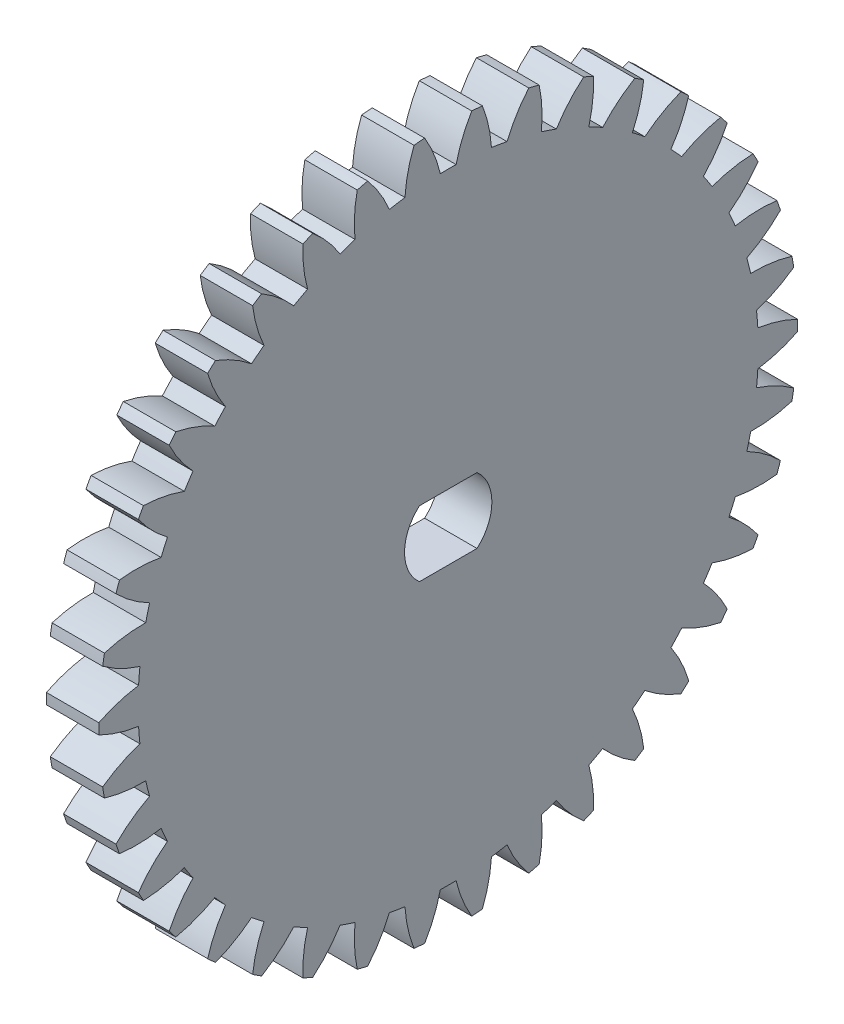
from build123d import *

# Parameters (mm, degrees)
BASPROSKE_W                 = 3
BASPROSKE_H                 = 20
TOOTHCUT_DEPTH              = 29.442925307
TEETHCUTS_COUNT             = 38
TEETHCUTS_ANGLE             = 350.526315789
BORSKE_R                    = 2.5
BORE_DEPTH                  = 50.0000508
SZKIC1_W                    = 8.825815256
SZKIC1_H                    = 6.337105314
SZKIC1_W_2                  = 5.5
SZKIC1_H_2                  = 3.760037978
DODANIE_WYCI_GNI_CIE1_DEPTH = 3


with BuildPart() as part:
    # BasProSke → Base-Revolve (revolve)
    with BuildSketch(Plane(origin=(0, 0, 0), x_dir=(1, 0, 0), z_dir=(0, 1, 0)), mode=Mode.PRIVATE) as base_revolve_sk:
        with Locations((1.5, 10)):
            Rectangle(BASPROSKE_W, BASPROSKE_H)
    revolve(base_revolve_sk.sketch.rotate(Axis((-10, 0, 0), (1, 0, 0)), 180), axis=Axis((-10, 0, 0), (1, 0, 0)))

    # TooCutSke → ToothCut (cut, through all)
    with BuildSketch(Plane(origin=(0, 0, 0), x_dir=(0, 0, -1), z_dir=(1, 0, 0))):
        with BuildLine():
            ThreePointArc((0.451522093, 17.743255868), (0, 17.749), (-0.451522093, 17.743255868))
            ThreePointArc((-0.451522093, 17.743255868), (-0.817150678, 18.897517772), (-1.361445068, 19.979066857))
            ThreePointArc((-1.361445068, 19.979066857), (0, 20.0254), (1.361445068, 19.979066857))
            ThreePointArc((1.361445068, 19.979066857), (0.817150678, 18.897517772), (0.451522093, 17.743255868))
        make_face()
    toothcut = extrude(amount=TOOTHCUT_DEPTH, mode=Mode.SUBTRACT)

    # TeethCuts: ToothCut ×38 about axis
    teethcuts_axis = Axis((-10, 0, 0), (1, 0, 0))
    for i in range(1, TEETHCUTS_COUNT):
        add(toothcut.rotate(teethcuts_axis, i * TEETHCUTS_ANGLE / (TEETHCUTS_COUNT - 1)), mode=Mode.SUBTRACT)

    # BorSke → Bore (cut, symmetric)
    with BuildSketch(Plane(origin=(0, 0, 0), x_dir=(0, 0, -1), z_dir=(1, 0, 0))):
        with Locations(Location((0, 0, 0), (0, 0, 180))):
            Circle(BORSKE_R)
    extrude(amount=BORE_DEPTH, both=True, mode=Mode.SUBTRACT)

    # Szkic1 → Dodanie-wyciągnięcie1 (add)
    with BuildSketch(Plane.ZY):
        with Locations((0.076608337, 0.03154926)):
            Rectangle(SZKIC1_W, SZKIC1_H)
        with Locations((0.002753395, 0)):
            Rectangle(SZKIC1_W_2, SZKIC1_H_2, mode=Mode.SUBTRACT)
    extrude(amount=-DODANIE_WYCI_GNI_CIE1_DEPTH)


solid = part.part
